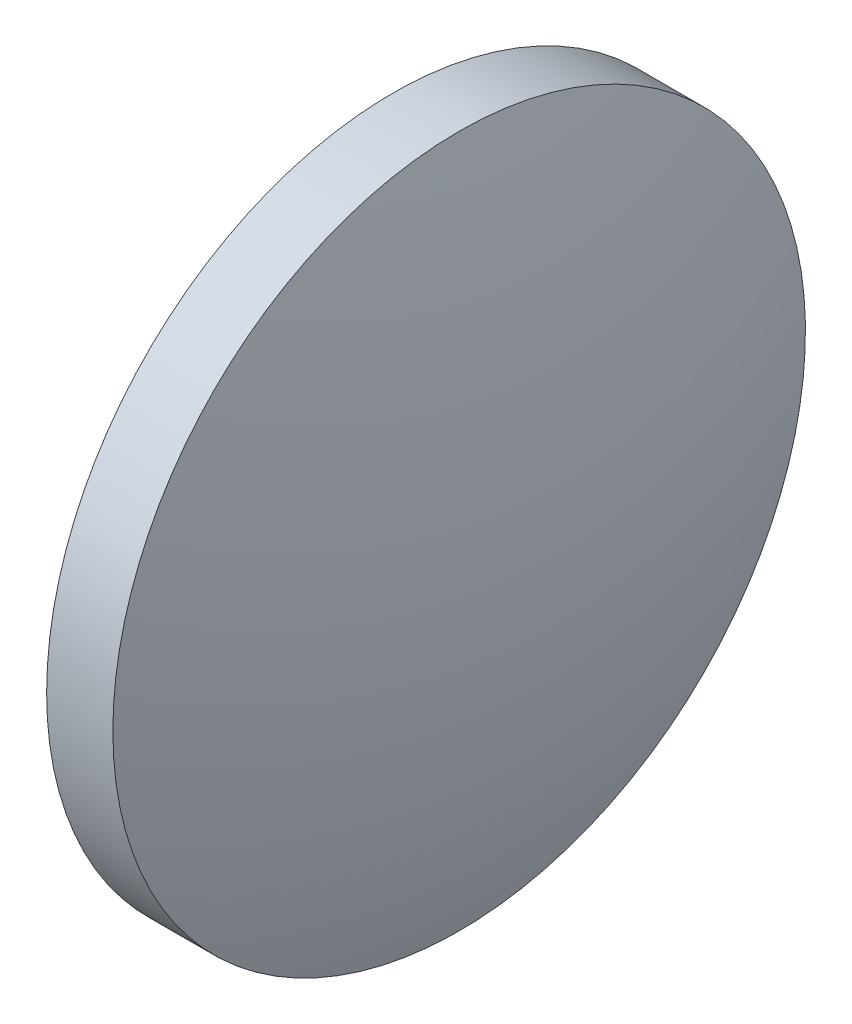
from build123d import *


with BuildPart() as part:
    # 草图1 → 旋转1 (revolve)
    with BuildSketch(Plane.XY):
        with BuildLine():
            Line((683.063550857, 205.990179432), (683.063550857, 213.990179432))
            Line((683.063550857, 213.990179432), (684.593550857, 213.990179432))
            ThreePointArc((684.593550857, 213.990179432), (685.544075299, 210.040268937), (685.863550857, 205.990179432))
            Line((685.863550857, 205.990179432), (683.063550857, 205.990179432))
        make_face()
    revolve(axis=Axis((679.338282237, 205.990179432, 0), (1, 0, 0)))


solid = part.part
